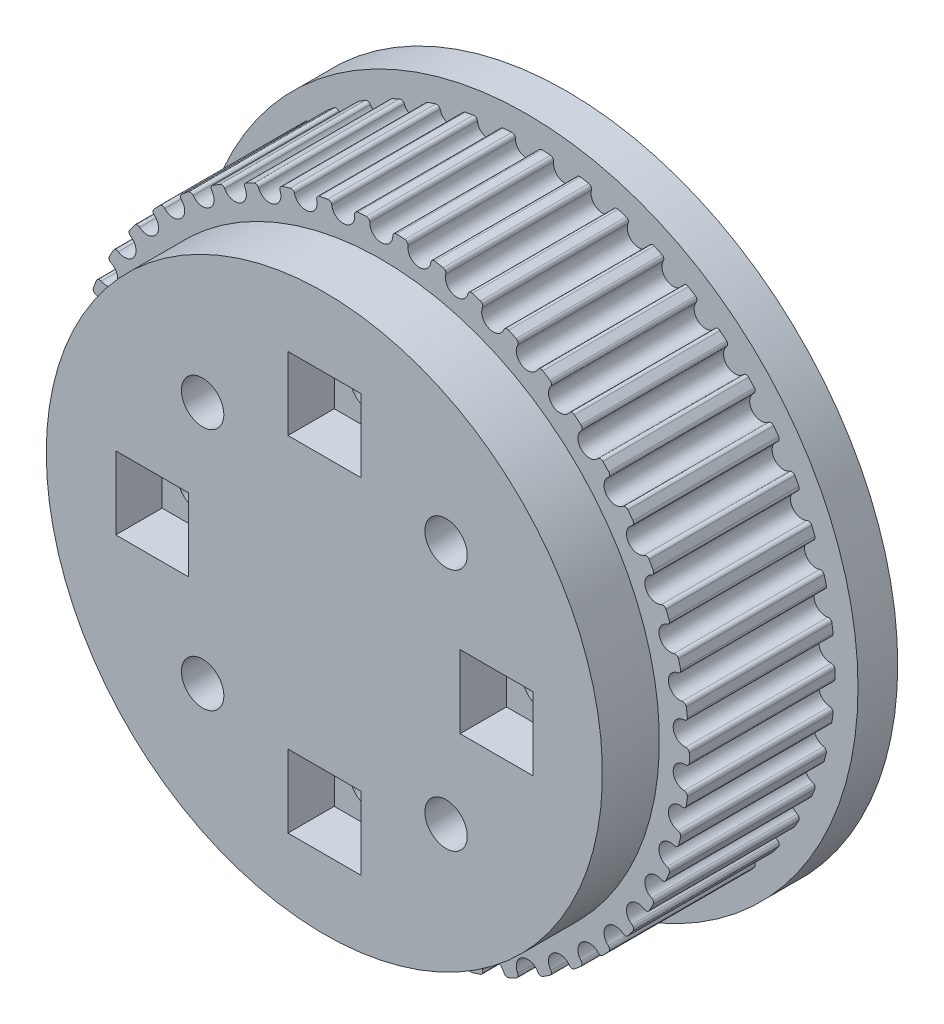
from build123d import *

# Parameters (mm, degrees)
BOSS_EXTRUDE1_START      = 3
BOSS_EXTRUDE1_DEPTH      = 11
FILLET1_R                = 0.26
CIRPATTERN1_COUNT        = 50
FILLET1_OF_CIRPATTERN1_R = 0.26
SKETCH2_R                = 25
SKETCH2_R_2              = 21
BOSS_EXTRUDE2_DEPTH      = 3
BOSS_EXTRUDE3_START      = 14
SKETCH2_3_R              = 21
BOSS_EXTRUDE3_DEPTH      = 4.3
SKETCH3_R                = 1.6
CUT_EXTRUDE1_DEPTH       = 40.810677085
CUT_EXTRUDE1_DEPTH_BACK  = 40.810677085
SKETCH3_3_W              = 5.5
SKETCH3_3_H              = 5.5
SKETCH3_3_R              = 1.6
CUT_EXTRUDE2_DEPTH       = 40.810677085
CUT_EXTRUDE2_DEPTH_BACK  = 3.5
SKETCH4_R                = 1.6
CUT_EXTRUDE3_DEPTH       = 40.810677085
SKETCH4_3_W              = 5.5
SKETCH4_3_H              = 5.5
SKETCH4_3_R              = 1.6
CUT_EXTRUDE4_DEPTH       = 3


with BuildPart() as part:
    # Sketch1 → Boss-Extrude1 (new body)
    with BuildSketch(Plane(origin=(0, 0, 0), x_dir=(0, 1, 0), z_dir=(0, 0, 1)).offset(BOSS_EXTRUDE1_START)):
        with BuildLine():
            Line((0, 0), (0, 23.258241464))
            ThreePointArc((0, 23.258241464), (0.319668882, 23.256044543), (0.639277374, 23.249454196))
            ThreePointArc((0.639277374, 23.249454196), (1.386932157, 22.044655365), (2.279692792, 23.146248006))
            ThreePointArc((2.279692792, 23.146248006), (2.597607065, 23.11272882), (2.91503061, 23.074843283))
            Line((2.91503061, 23.074843283), (0, 0))
        make_face()
    boss_extrude1 = extrude(amount=BOSS_EXTRUDE1_DEPTH)

    # Fillet1
    fillet1_edges = [part.edges().sort_by_distance(p)[0] for p in [
        (-23.249454196, 0.639277374, 8.5),
        (-23.146248006, 2.279692792, 8.5),
    ]]
    fillet(fillet1_edges, radius=FILLET1_R)

    # CirPattern1: Boss-Extrude1 ×50 about axis
    cirpattern1_axis = Axis((0, 0, 0), (0, 0, 1))
    for i in range(1, CIRPATTERN1_COUNT):
        add(boss_extrude1.rotate(cirpattern1_axis, i * 360 / CIRPATTERN1_COUNT))

    # Fillet1 of CirPattern1
    fillet1_of_cirpattern1_edges = [part.edges().sort_by_distance(p)[0] for p in [
        (-23.146248006, -2.279692792, 8.5),
        (-23.249454196, -0.639277374, 8.5),
        (-22.678011658, -5.162710841, 8.5),
        (-22.986002605, -3.548165754, 8.5),
        (-21.852129519, -7.964309856, 8.5),
        (-22.360048022, -6.40109744, 8.5),
        (-20.681626243, -10.640306947, 8.5),
        (-21.381462124, -9.153079997, 8.5),
        (-19.184961367, -13.148500041, 8.5),
        (-20.065677796, -11.760713013, 8.5),
        (-17.38573819, -15.449333435, 8.5),
        (-18.433445742, -14.18287256, 8.5),
        (-15.312331536, -17.506521611, 8.5),
        (-16.510507238, -16.381359734, 8.5),
        (-12.997440266, -19.287621484, 8.5),
        (-14.327188171, -18.32150308, 8.5),
        (-10.477571599, -20.764544044, 8.5),
        (-11.917920788, -19.972705377, 8.5),
        (-7.792465369, -21.913997341, 8.5),
        (-9.320700675, -21.308926179, 8.5),
        (-4.984467305, -22.717853809, 8.5),
        (-6.576487544, -22.309092486, 8.5),
        (-2.097861214, -23.163436151, 8.5),
        (-3.728559277, -22.957431078, 8.5),
        (0.821829402, -23.243717268, 8.5),
        (-0.821829402, -23.243717268, 8.5),
        (3.728559277, -22.957431078, 8.5),
        (2.097861214, -23.163436151, 8.5),
        (6.576487544, -22.309092486, 8.5),
        (4.984467305, -22.717853809, 8.5),
        (9.320700675, -21.308926179, 8.5),
        (7.792465369, -21.913997341, 8.5),
        (11.917920788, -19.972705377, 8.5),
        (10.477571599, -20.764544044, 8.5),
        (14.327188171, -18.32150308, 8.5),
        (12.997440266, -19.287621484, 8.5),
        (16.510507238, -16.381359734, 8.5),
        (15.312331536, -17.506521611, 8.5),
        (18.433445742, -14.18287256, 8.5),
        (17.38573819, -15.449333435, 8.5),
        (20.065677796, -11.760713013, 8.5),
        (19.184961367, -13.148500041, 8.5),
        (21.381462124, -9.153079997, 8.5),
        (20.681626243, -10.640306947, 8.5),
        (22.360048022, -6.40109744, 8.5),
        (21.852129519, -7.964309856, 8.5),
        (22.986002605, -3.548165754, 8.5),
        (22.678011658, -5.162710841, 8.5),
        (23.249454196, -0.639277374, 8.5),
        (23.146248006, -2.279692792, 8.5),
        (23.146248006, 2.279692792, 8.5),
        (23.249454196, 0.639277374, 8.5),
        (22.678011658, 5.162710841, 8.5),
        (22.986002605, 3.548165754, 8.5),
        (21.852129519, 7.964309856, 8.5),
        (22.360048022, 6.40109744, 8.5),
        (20.681626243, 10.640306947, 8.5),
        (21.381462124, 9.153079997, 8.5),
        (19.184961367, 13.148500041, 8.5),
        (20.065677796, 11.760713013, 8.5),
        (17.38573819, 15.449333435, 8.5),
        (18.433445742, 14.18287256, 8.5),
        (15.312331536, 17.506521611, 8.5),
        (16.510507238, 16.381359734, 8.5),
        (12.997440266, 19.287621484, 8.5),
        (14.327188171, 18.32150308, 8.5),
        (10.477571599, 20.764544044, 8.5),
        (11.917920788, 19.972705377, 8.5),
        (7.792465369, 21.913997341, 8.5),
        (9.320700675, 21.308926179, 8.5),
        (4.984467305, 22.717853809, 8.5),
        (6.576487544, 22.309092486, 8.5),
        (2.097861214, 23.163436151, 8.5),
        (3.728559277, 22.957431078, 8.5),
        (-0.821829402, 23.243717268, 8.5),
        (0.821829402, 23.243717268, 8.5),
        (-3.728559277, 22.957431078, 8.5),
        (-2.097861214, 23.163436151, 8.5),
        (-6.576487544, 22.309092486, 8.5),
        (-4.984467305, 22.717853809, 8.5),
        (-9.320700675, 21.308926179, 8.5),
        (-7.792465369, 21.913997341, 8.5),
        (-11.917920788, 19.972705377, 8.5),
        (-10.477571599, 20.764544044, 8.5),
        (-14.327188171, 18.32150308, 8.5),
        (-12.997440266, 19.287621484, 8.5),
        (-16.510507238, 16.381359734, 8.5),
        (-15.312331536, 17.506521611, 8.5),
        (-18.433445742, 14.18287256, 8.5),
        (-17.38573819, 15.449333435, 8.5),
        (-20.065677796, 11.760713013, 8.5),
        (-19.184961367, 13.148500041, 8.5),
        (-21.381462124, 9.153079997, 8.5),
        (-20.681626243, 10.640306947, 8.5),
        (-22.360048022, 6.40109744, 8.5),
        (-21.852129519, 7.964309856, 8.5),
        (-22.986002605, 3.548165754, 8.5),
        (-22.678011658, 5.162710841, 8.5),
    ]]
    fillet(fillet1_of_cirpattern1_edges, radius=FILLET1_OF_CIRPATTERN1_R)

    # Sketch2 → Boss-Extrude2 (add)
    with BuildSketch(Plane(origin=(0, 0, 0), x_dir=(0, 1, 0), z_dir=(0, 0, 1))):
        with Locations(Location((0, 0, 0), (0, 0, 90))):
            Circle(SKETCH2_R)
        Circle(SKETCH2_R_2, mode=Mode.SUBTRACT)
        Circle(SKETCH2_R_2)
    extrude(amount=BOSS_EXTRUDE2_DEPTH)

    # Sketch2_3 → Boss-Extrude3 (add)
    with BuildSketch(Plane(origin=(0, 0, 0), x_dir=(0, 1, 0), z_dir=(0, 0, 1)).offset(BOSS_EXTRUDE3_START)):
        with Locations(Location((0, 0, 0), (0, 0, 90))):
            Circle(SKETCH2_3_R)
    extrude(amount=BOSS_EXTRUDE3_DEPTH)

    # Sketch3 → Cut-Extrude1 (cut, two sides)
    with BuildSketch(Plane.XY.offset(18.3)) as cut_extrude1_sk:
        with Locations((0, 13)):
            Circle(SKETCH3_R)
        with Locations((13, 0)):
            Circle(SKETCH3_R)
        with Locations((0, -13)):
            Circle(SKETCH3_R)
        with Locations((-13, 0)):
            Circle(SKETCH3_R)
    extrude(amount=CUT_EXTRUDE1_DEPTH, mode=Mode.SUBTRACT)
    extrude(cut_extrude1_sk.sketch, amount=-CUT_EXTRUDE1_DEPTH_BACK, mode=Mode.SUBTRACT)

    # Sketch3_3 → Cut-Extrude2 (cut, two sides)
    with BuildSketch(Plane.XY.offset(18.3)) as cut_extrude2_sk:
        with Locations((-13, 0)):
            Rectangle(SKETCH3_3_W, SKETCH3_3_H)
        with Locations((-13, 0)):
            Circle(SKETCH3_3_R, mode=Mode.SUBTRACT)
        with Locations((-13, 0)):
            Circle(SKETCH3_3_R)
        with Locations((0, 13)):
            Rectangle(SKETCH3_3_W, SKETCH3_3_H)
        with Locations((0, 13)):
            Circle(SKETCH3_3_R, mode=Mode.SUBTRACT)
        with Locations((0, 13)):
            Circle(SKETCH3_3_R)
        with Locations((13, 0)):
            Rectangle(SKETCH3_3_W, SKETCH3_3_H)
        with Locations((13, 0)):
            Circle(SKETCH3_3_R, mode=Mode.SUBTRACT)
        with Locations((0, -13)):
            Rectangle(SKETCH3_3_W, SKETCH3_3_H)
        with Locations((0, -13)):
            Circle(SKETCH3_3_R, mode=Mode.SUBTRACT)
        with Locations((0, -13)):
            Circle(SKETCH3_3_R)
        with Locations((13, 0)):
            Circle(SKETCH3_3_R)
    extrude(amount=CUT_EXTRUDE2_DEPTH, mode=Mode.SUBTRACT)
    extrude(cut_extrude2_sk.sketch, amount=-CUT_EXTRUDE2_DEPTH_BACK, mode=Mode.SUBTRACT)

    # Sketch4 → Cut-Extrude3 (cut, through all)
    with BuildSketch(Plane(origin=(0, 0, 0), x_dir=(1, 0, 0), z_dir=(0, 0, -1))):
        with Locations(Location((-9.192388155, 9.192388155, 0), (0, 0, 180))):
            Circle(SKETCH4_R)
        with Locations(Location((9.192388155, 9.192388155, 0), (0, 0, 180))):
            Circle(SKETCH4_R)
        with Locations(Location((9.192388155, -9.192388155, 0), (0, 0, 180))):
            Circle(SKETCH4_R)
        with Locations(Location((-9.192388155, -9.192388155, 0), (0, 0, 180))):
            Circle(SKETCH4_R)
    extrude(amount=-CUT_EXTRUDE3_DEPTH, mode=Mode.SUBTRACT)

    # Sketch4_3 → Cut-Extrude4 (cut)
    with BuildSketch(Plane(origin=(0, 0, 0), x_dir=(1, 0, 0), z_dir=(0, 0, -1))):
        with Locations((9.192388155, -9.192388155)):
            Rectangle(SKETCH4_3_W, SKETCH4_3_H)
        with Locations(Location((9.192388155, -9.192388155, 0), (0, 0, 180))):
            Circle(SKETCH4_3_R, mode=Mode.SUBTRACT)
        with Locations((9.192388155, 9.192388155)):
            Rectangle(SKETCH4_3_W, SKETCH4_3_H)
        with Locations(Location((9.192388155, 9.192388155, 0), (0, 0, 180))):
            Circle(SKETCH4_3_R, mode=Mode.SUBTRACT)
        with Locations((-9.192388155, -9.192388155)):
            Rectangle(SKETCH4_3_W, SKETCH4_3_H)
        with Locations(Location((-9.192388155, -9.192388155, 0), (0, 0, 180))):
            Circle(SKETCH4_3_R, mode=Mode.SUBTRACT)
        with Locations((-9.192388155, 9.192388155)):
            Rectangle(SKETCH4_3_W, SKETCH4_3_H)
        with Locations(Location((-9.192388155, 9.192388155, 0), (0, 0, 180))):
            Circle(SKETCH4_3_R, mode=Mode.SUBTRACT)
    extrude(amount=-CUT_EXTRUDE4_DEPTH, mode=Mode.SUBTRACT)


solid = part.part
